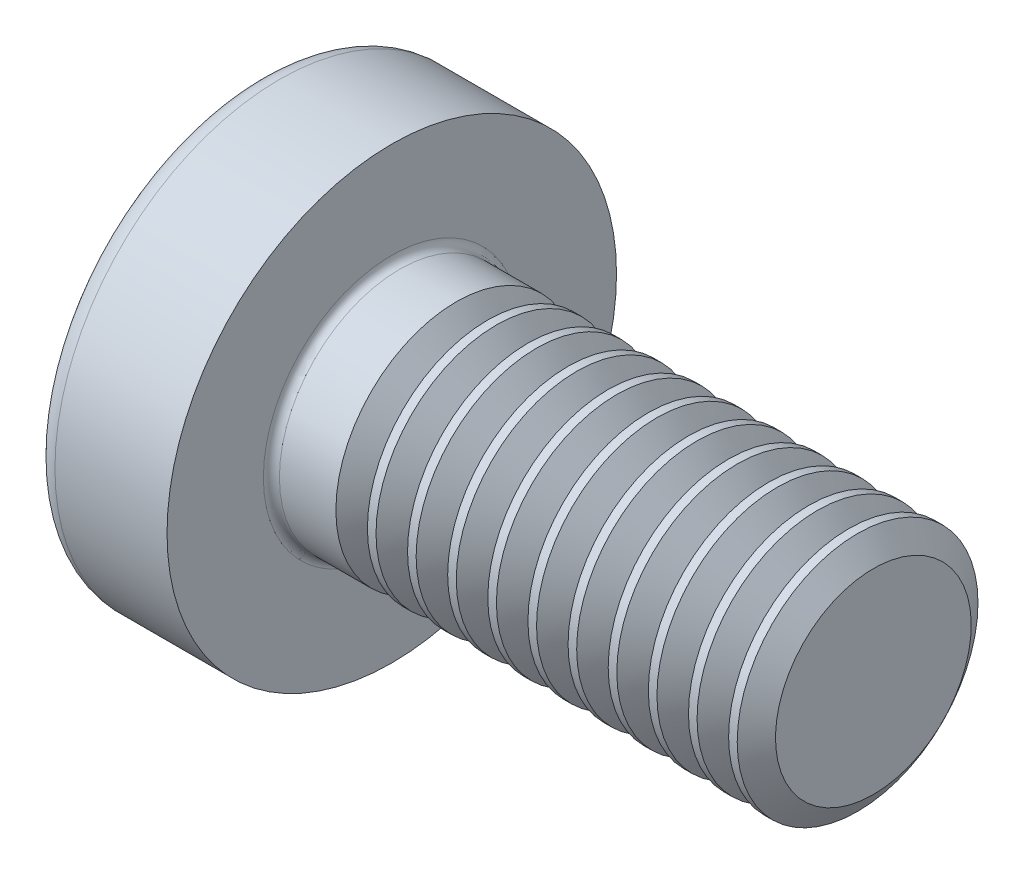
from build123d import *

# Parameters (mm, degrees)
FILLET1_R       = 0.1
SKETCH3_W       = 0.74
SKETCH3_H       = 2.8
SKETCH4_W       = 0.74
SKETCH4_H       = 1.054964664
RECPAT_COUNT    = 2
RECPAT_ANGLE    = 90
THDSCHPAT_COUNT = 11
THDSCHPAT_PITCH = 0.5


with BuildPart() as part:
    # BodySke → Base-Revolve (revolve)
    with BuildSketch(Plane.XY, mode=Mode.PRIVATE) as base_revolve_sk:
        with BuildLine():
            Line((2.4, 1.5), (2.4, 2.8))
            Line((2.4, 2.8), (1.003501533, 2.8))
            ThreePointArc((1.003501533, 2.8), (0.873295971, 2.76653015), (0.775371599, 2.674418605))
            ThreePointArc((0.775371599, 2.674418605), (0.197753546, 1.392274756), (0, 0))
            Line((0, 0), (8.4, 0))
            Line((8.4, 0), (8.4, 1.5))
            Line((8.4, 1.5), (2.4, 1.5))
        make_face()
    revolve(base_revolve_sk.sketch.rotate(Axis((-25.4, 0, 0), (1, 0, 0)), 90), axis=Axis((-25.4, 0, 0), (1, 0, 0)))  # turned: the seam where the file's is

    # Fillet1
    fillet1_edges = [part.edges().sort_by_distance(p)[0] for p in [
        (2.4, 0, -1.5),
    ]]
    fillet(fillet1_edges, radius=FILLET1_R)

    # Sketch3 → Recess section 0
    with BuildSketch(Plane(origin=(0, 0, 0), x_dir=(0, 0, -1), z_dir=(1, 0, 0))):
        Rectangle(SKETCH3_W, SKETCH3_H)
    # Sketch4 → Recess section 1
    with BuildSketch(Plane(origin=(1.75, 0, 0), x_dir=(0, 0, -1), z_dir=(1, 0, 0))):
        Rectangle(SKETCH4_W, SKETCH4_H)
    recess = loft(mode=Mode.SUBTRACT)

    # RecPat: Recess ×2 about axis
    recpat_axis = Axis((0, 0, 0), (1, 0, 0))
    for i in range(1, RECPAT_COUNT):
        add(recess.rotate(recpat_axis, i * RECPAT_ANGLE / (RECPAT_COUNT - 1)), mode=Mode.SUBTRACT)

    # RecCorSke → RecessCore (revolve, cut)
    with BuildSketch(Plane.XY, mode=Mode.PRIVATE) as recesscore_sk:
        Polygon((0, 0), (0, 0.678371921), (1.75, 0.556), (1.930655351, 0), align=None)
    revolve(recesscore_sk.sketch.rotate(Axis((-3.175, 0, 0), (1, 0, 0)), 90), axis=Axis((-3.175, 0, 0), (1, 0, 0)), mode=Mode.SUBTRACT)  # turned: the seam where the file's is

    # ThdSchSke → ThreadSchematic (revolve, cut)
    with BuildSketch(Plane.XY, mode=Mode.PRIVATE) as threadschematic_sk:
        Polygon((3.4, -1.2195), (3.203591786, -1.5), (3.203591786, -1.875), (3.596408214, -1.875), (3.596408214, -1.5), align=None)
    threadschematic = revolve(threadschematic_sk.sketch.rotate(Axis((-3.175, 0, 0), (1, 0, 0)), 270), axis=Axis((-3.175, 0, 0), (1, 0, 0)), mode=Mode.SUBTRACT)  # turned: the seam where the file's is

    # ThdSchPat: ThreadSchematic ×11
    with Locations(*[(i * THDSCHPAT_PITCH, 0, 0) for i in range(1, THDSCHPAT_COUNT)]):
        add(threadschematic, mode=Mode.SUBTRACT)


solid = part.part
